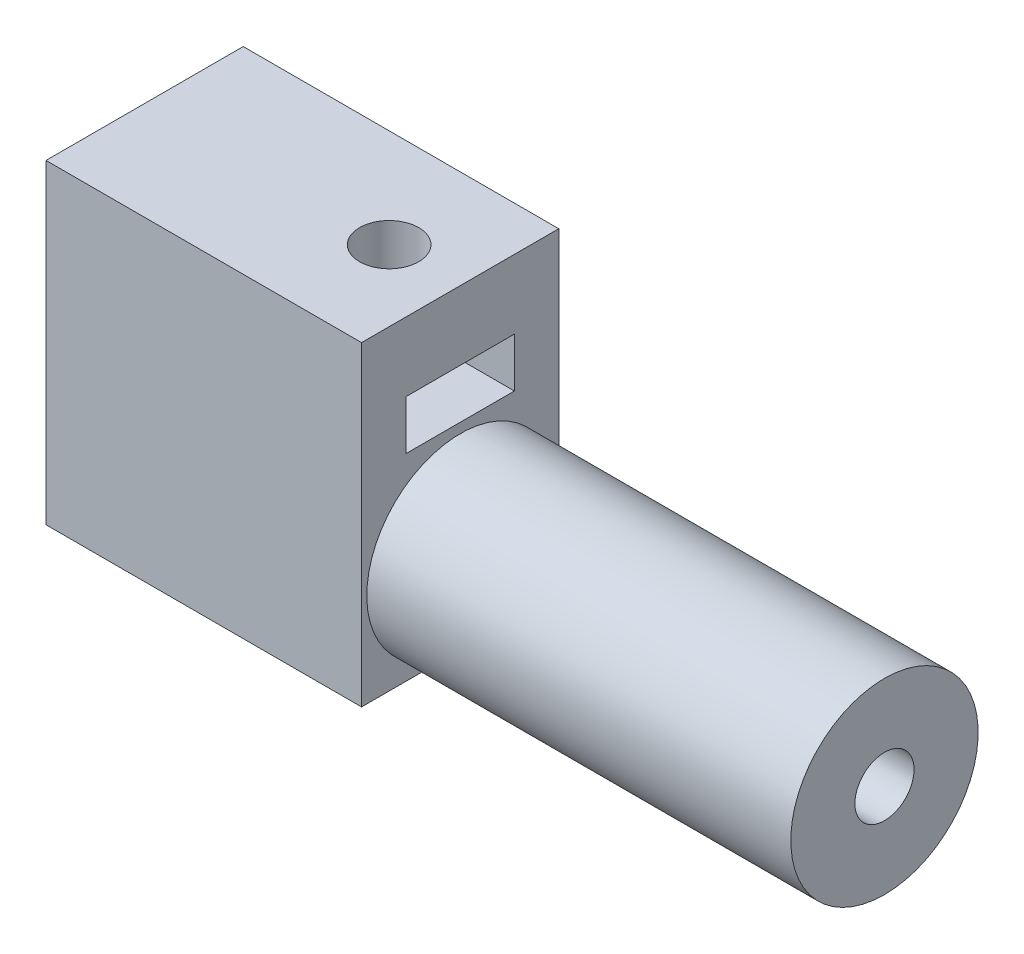
from build123d import *

# Parameters (mm, degrees)
SKETCH1_W           = 16
SKETCH1_H           = 16
BOSS_EXTRUDE1_DEPTH = 10
SKETCH2_R           = 1.5
CUT_EXTRUDE1_DEPTH  = 6
SKETCH3_R           = 1.5
CUT_EXTRUDE2_DEPTH  = 6
CUT_EXTRUDE3_START  = -3.5
CUT_EXTRUDE3_DEPTH  = 2.5
CUT_EXTRUDE5_START  = -3.5
SKETCH6_W           = 5.5
SKETCH6_H           = 8.06
CUT_EXTRUDE5_DEPTH  = 2.5
CUT_EXTRUDE6_START  = -3.5
SKETCH7_W           = 7.078957324
SKETCH7_H           = 5.4986679
CUT_EXTRUDE6_DEPTH  = 2.5
SKETCH9_R           = 4.75
BOSS_EXTRUDE2_DEPTH = 21.5
SKETCH10_R          = 1.5
CUT_EXTRUDE7_DEPTH  = 6
CUT_EXTRUDE9_START  = -3.5
SKETCH11_R          = 1.5
CUT_EXTRUDE9_DEPTH  = 2.5


with BuildPart() as part:
    # Sketch1 → Boss-Extrude1 (new body)
    with BuildSketch(Plane.XY):
        Rectangle(SKETCH1_W, SKETCH1_H)
    extrude(amount=BOSS_EXTRUDE1_DEPTH)

    # Sketch2 → Cut-Extrude1 (cut)
    with BuildSketch(Plane.ZY.offset(8)):
        with Locations(Location((5, -3.97, 0), (0, 0, 270))):
            Circle(SKETCH2_R)
    extrude(amount=-CUT_EXTRUDE1_DEPTH, mode=Mode.SUBTRACT)

    # Sketch3 → Cut-Extrude2 (cut)
    with BuildSketch(Plane(origin=(0, 8, 0), x_dir=(1, 0, 0), z_dir=(0, 1, 0))):
        with Locations(Location((4.4, -5, 0), (0, 0, 270))):
            Circle(SKETCH3_R)
    extrude(amount=-CUT_EXTRUDE2_DEPTH, mode=Mode.SUBTRACT)

    # Sketch4 → Cut-Extrude3 (cut)
    with BuildSketch(Plane.ZY.offset(8).offset(CUT_EXTRUDE3_START)):
        Polygon((7.75, -2.38228676), (5, -0.794573519), (2.25, -2.38228676), (2.25, -5.55771324), (5, -7.145426481), (7.75, -5.55771324), align=None)
    extrude(amount=-CUT_EXTRUDE3_DEPTH, mode=Mode.SUBTRACT)

    # Sketch6 → Cut-Extrude5 (cut)
    with BuildSketch(Plane.ZY.offset(8).offset(CUT_EXTRUDE5_START)):
        with Locations((5, -8)):
            Rectangle(SKETCH6_W, SKETCH6_H)
    extrude(amount=-CUT_EXTRUDE5_DEPTH, mode=Mode.SUBTRACT)

    # Sketch7 → Cut-Extrude6 (cut)
    with BuildSketch(Plane(origin=(0, 8, 0), x_dir=(1, 0, 0), z_dir=(0, 1, 0)).offset(CUT_EXTRUDE6_START)):
        Polygon((7.574657392, -5.069884021), (6.047850034, -2.285608061), (2.873192642, -2.21572404), (1.225342608, -4.930115979), (2.752149966, -7.714391939), (5.926807358, -7.78427596), align=None)
        with Locations((8, -5)):
            Rectangle(SKETCH7_W, SKETCH7_H)
    extrude(amount=-CUT_EXTRUDE6_DEPTH, mode=Mode.SUBTRACT)

    # Sketch9 → Boss-Extrude2 (add)
    with BuildSketch(Plane(origin=(8, 0, 0), x_dir=(0, 0, -1), z_dir=(1, 0, 0))):
        with Locations(Location((-4.985464698, -3.25, 0), (0, 0, 270))):
            Circle(SKETCH9_R)
    extrude(amount=BOSS_EXTRUDE2_DEPTH)

    # Sketch10 → Cut-Extrude7 (cut)
    with BuildSketch(Plane(origin=(29.5, 0, 0), x_dir=(0, 0, -1), z_dir=(1, 0, 0))):
        with Locations(Location((-4.985464698, -3.25, 0), (0, 0, 90))):
            Circle(SKETCH10_R)
    extrude(amount=-CUT_EXTRUDE7_DEPTH, mode=Mode.SUBTRACT)

    # Sketch11 → Cut-Extrude9 (cut)
    with BuildSketch(Plane(origin=(29.5, 0, 0), x_dir=(0, 0, -1), z_dir=(1, 0, 0)).offset(CUT_EXTRUDE9_START)):
        with BuildLine():
            Line((-2.31047639, -1.538926979), (-5.129803248, -0.07785566))
            Line((-5.129803248, -0.07785566), (-7.804791556, -1.78892868))
            Line((-7.804791556, -1.78892868), (-7.738307115, -3.250064634))
            Line((-7.738307115, -3.250064634), (-7.738307115, -7.120963527))
            ThreePointArc((-7.738307115, -7.120963527), (-4.988950766, -7.999998721), (-2.238307115, -7.125000027))
            Line((-2.238307115, -7.125000027), (-2.238307115, -3.12499915))
            Line((-2.238307115, -3.12499915), (-2.31047639, -1.538926979))
        make_face()
        with Locations(Location((-4.985464698, -3.25, 0), (0, 0, 90))):
            Circle(SKETCH11_R, mode=Mode.SUBTRACT)
    extrude(amount=-CUT_EXTRUDE9_DEPTH, mode=Mode.SUBTRACT)


solid = part.part
